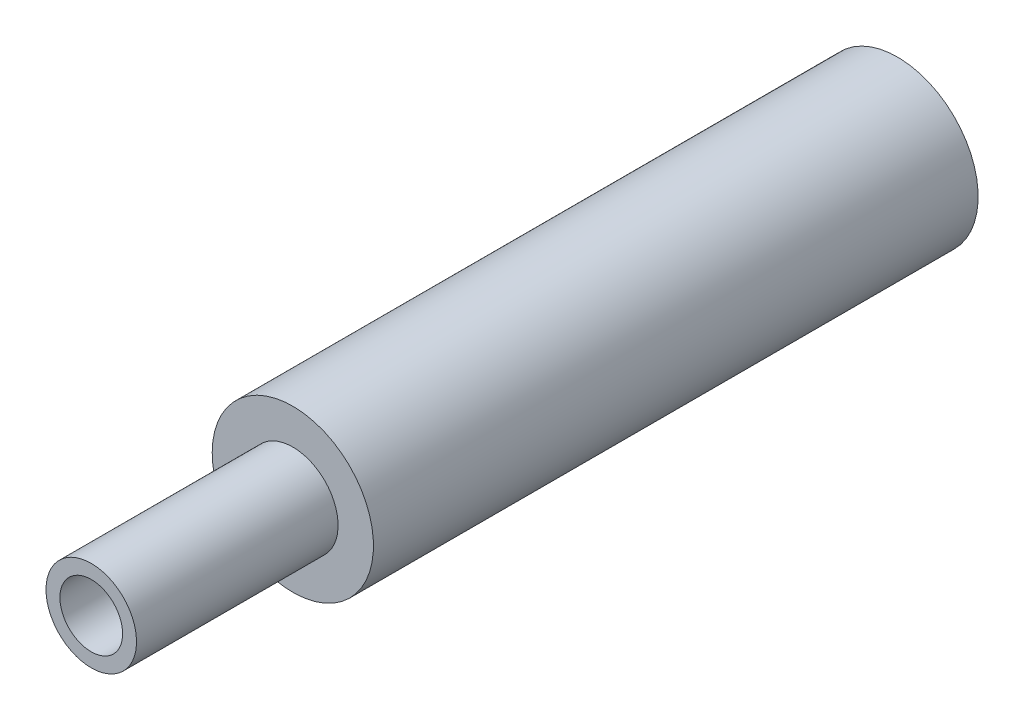
from build123d import *


with BuildPart() as part:
    # Sketch1 → Revolve1 (revolve)
    with BuildSketch(Plane.XZ):
        Polygon((0.777669257, 17), (0, 17), (0, 10), (1.475, 10), (1.475, 0), (2, 0), (2, 15), (1.12260037, 15), (1.12260037, 20), (0.777669257, 20), align=None)
    revolve(axis=Axis((0, 0, 20), (0, 0, -1)))


solid = part.part
